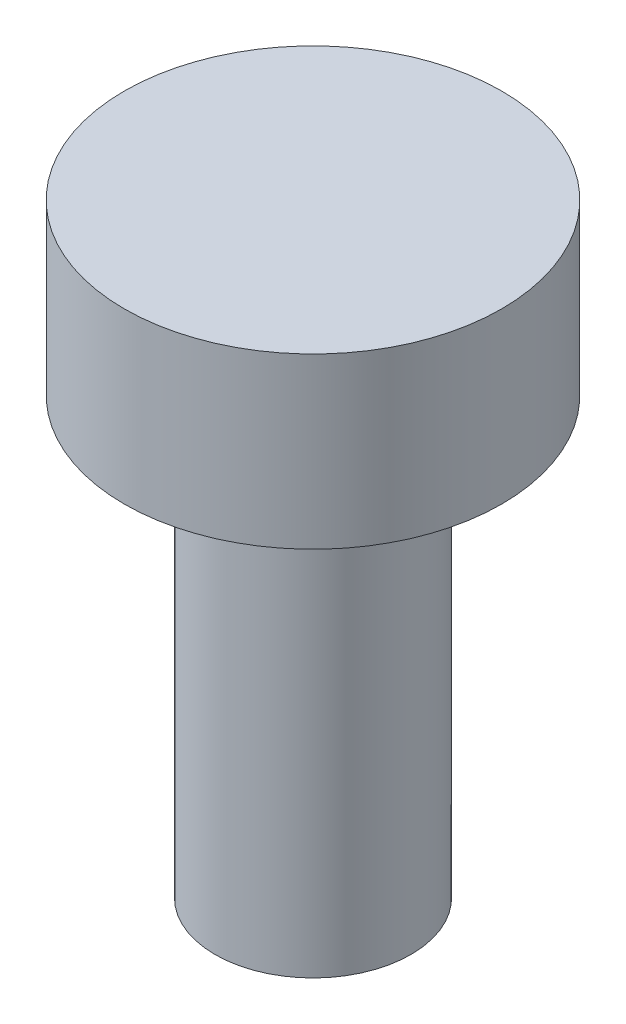
from build123d import *

# Parameters (mm, degrees)
SKETCH1_R           = 1.35
BOSS_EXTRUDE1_DEPTH = 6
SKETCH2_R           = 2.6
BOSS_EXTRUDE2_DEPTH = 2.33


with BuildPart() as part:
    # Sketch1 → Boss-Extrude1 (new body)
    with BuildSketch(Plane(origin=(0, 0, 0), x_dir=(1, 0, 0), z_dir=(0, 1, 0))):
        Circle(SKETCH1_R)
    extrude(amount=BOSS_EXTRUDE1_DEPTH)

    # Sketch2 → Boss-Extrude2 (add)
    with BuildSketch(Plane(origin=(0, 6, 0), x_dir=(1, 0, 0), z_dir=(0, 1, 0))):
        Circle(SKETCH2_R)
    extrude(amount=BOSS_EXTRUDE2_DEPTH)


solid = part.part
